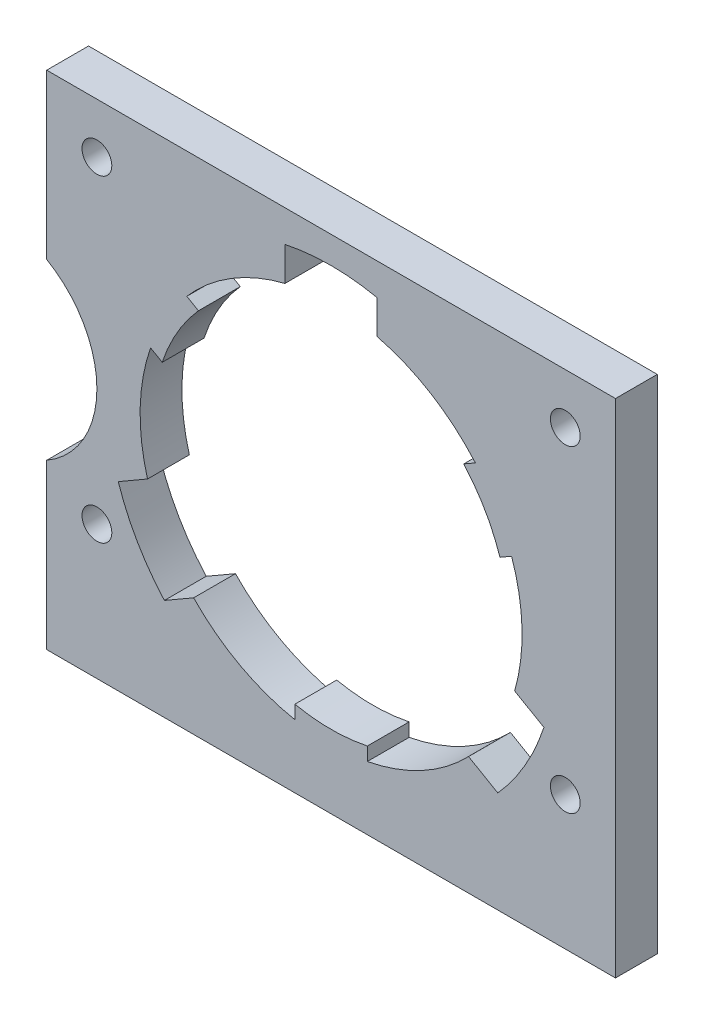
from build123d import *

# Parameters (mm, degrees)
SKETCH1_W             = 43.18
SKETCH1_H             = 38.1
BOSS_EXTRUDE1_DEPTH   = 3.175
SKETCH2_R             = 14.5
CUT_EXTRUDE1_DEPTH    = 4.175
CUT_EXTRUDE2_DEPTH    = 4.175
CIRPATTERN1_COUNT     = 3
BOSS_EXTRUDE2_DEPTH   = 3.175
CIRPATTERN2_COUNT     = 3
SKETCH6_R             = 7.62
CUT_EXTRUDE4_DEPTH    = 4.175
F_4_40_TAPPED_HOLE1_D = 2.2606


with BuildPart() as part:
    # Sketch1 → Boss-Extrude1 (new body)
    with BuildSketch(Plane.XY):
        Rectangle(SKETCH1_W, SKETCH1_H)
    extrude(amount=BOSS_EXTRUDE1_DEPTH)

    # Sketch2 → Cut-Extrude1 (cut, through all)
    with BuildSketch(Plane.XY.offset(3.175)):
        Circle(SKETCH2_R)
    extrude(amount=-CUT_EXTRUDE1_DEPTH, mode=Mode.SUBTRACT)

    # Sketch3 → Cut-Extrude2 (cut, through all)
    with BuildSketch(Plane.XY.offset(3.175)):
        with BuildLine():
            Line((-3.5, 16.63580476), (-3.5, 14.071247279))
            ThreePointArc((-3.5, 14.071247279), (0, 14.5), (3.5, 14.071247279))
            Line((3.5, 14.071247279), (3.5, 16.63580476))
            ThreePointArc((3.5, 16.63580476), (0, 17), (-3.5, 16.63580476))
        make_face()
    cut_extrude2 = extrude(amount=-CUT_EXTRUDE2_DEPTH, mode=Mode.SUBTRACT)

    # CirPattern1: Cut-Extrude2 ×3 about axis
    cirpattern1_axis = Axis((0, 0, 0), (0, 0, 1))
    for i in range(1, CIRPATTERN1_COUNT):
        add(cut_extrude2.rotate(cirpattern1_axis, i * 360 / CIRPATTERN1_COUNT), mode=Mode.SUBTRACT)

    # Sketch4 → Boss-Extrude2 (add)
    with BuildSketch(Plane.XY.offset(3.175)):
        with BuildLine():
            Line((-2.75, -13.216939888), (-2.75, -14.236836025))
            ThreePointArc((-2.75, -14.236836025), (0, -14.5), (2.75, -14.236836025))
            Line((2.75, -14.236836025), (2.75, -13.216939888))
            ThreePointArc((2.75, -13.216939888), (0, -13.5), (-2.75, -13.216939888))
        make_face()
    boss_extrude2 = extrude(amount=-BOSS_EXTRUDE2_DEPTH)

    # CirPattern2: Boss-Extrude2 ×3 about axis
    cirpattern2_axis = Axis((0, 0, 0), (0, 0, 1))
    for i in range(1, CIRPATTERN2_COUNT):
        add(boss_extrude2.rotate(cirpattern2_axis, i * 360 / CIRPATTERN2_COUNT))

    # Sketch6 → Cut-Extrude4 (cut, through all)
    with BuildSketch(Plane.XY.offset(3.175)):
        with Locations((-25.4, 0)):
            Circle(SKETCH6_R)
    extrude(amount=-CUT_EXTRUDE4_DEPTH, mode=Mode.SUBTRACT)

    # #4-40 Tapped Hole1 (through all)
    with Locations(Plane(origin=(0, 0, 0), x_dir=(-1, 0, 0), z_dir=(0, 0, -1))):
        with Locations((-17.78, 15.24), (-17.78, -8.89), (17.78, -8.89), (17.78, 15.24)):
            Hole(F_4_40_TAPPED_HOLE1_D / 2)


solid = part.part
